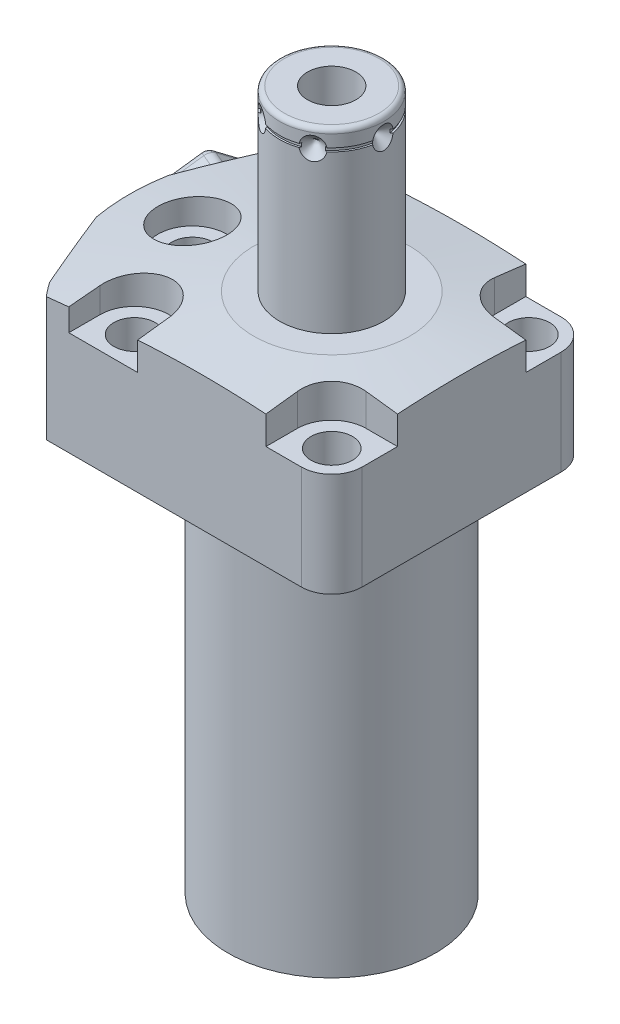
from build123d import *

# Parameters (mm, degrees)
CUT_EXTRUDE1_DEPTH       = 32.9946
CUT_EXTRUDE2_DEPTH       = 30.1498
CUT_EXTRUDE3_DEPTH       = 32.9946
FILLET1_R                = 6.477
CUT_EXTRUDE4_DEPTH       = 8.001
SKETCH11_R               = 2.7432
EXTRUDE1_DEPTH           = 2.9972
CUT_EXTRUDE5_DEPTH       = 1.27
CHAMFER1_SIZE            = 0.254
CHAMFER1_OF_MIRROR2_SIZE = 0.254
SKETCH16_R               = 1
SKETCH19_R               = 8.5
EXTRUDE3_DEPTH           = 1
SKETCH22_W               = 0.381
SKETCH22_H               = 0.762
HOLE1_AT_2_COUNT         = 2
HOLE1_AT_2_PITCH         = 54.877785999
HOLE1_AT_3_COUNT         = 2
HOLE1_AT_3_PITCH         = 54.877785999
HOLE1_AT_4_COUNT         = 2
HOLE1_AT_4_PITCH         = 22.73112685
HOLE1_AT_5_COUNT         = 2
HOLE1_AT_5_PITCH         = 22.73112685
SKETCH25_R               = 11.3665
CUT_EXTRUDE7_DEPTH       = 1.524
EXTRUDE4_DEPTH           = 7.471
FILLET2_R                = 2
CIRPATTERN1_COUNT        = 6


with BuildPart() as part:
    # S2D0002 → Revolve1 (revolve)
    with BuildSketch(Plane.XY, mode=Mode.PRIVATE) as revolve1_sk:
        Polygon((-43.18, 0), (-43.18, 30.1498), (0, 30.1498), (0, -80.9752), (-22.098, -80.9752), (-22.098, 0), align=None)
    revolve(revolve1_sk.sketch.rotate(Axis((0, -3.4925, 0), (0, 1, 0)), 270), axis=Axis((0, -3.4925, 0), (0, 1, 0)))  # turned: the seam where the file's is

    # S2D0001 → Cut-Extrude1 (cut)
    with BuildSketch(Plane.XZ):
        with BuildLine():
            Line((-33.136049915, -27.686), (33.136049915, -27.686))
            ThreePointArc((33.136049915, -27.686), (0, -43.18), (-33.136049915, -27.686))
        make_face()
        with BuildLine():
            Line((33.136049915, 27.686), (-33.136049915, 27.686))
            ThreePointArc((-33.136049915, 27.686), (0, 43.18), (33.136049915, 27.686))
        make_face()
    extrude(amount=-CUT_EXTRUDE1_DEPTH, mode=Mode.SUBTRACT)

    # Sketch3 → Cut-Extrude2 (cut)
    with BuildSketch(Plane(origin=(0, 30.1498, 0), x_dir=(-1, 0, 0), z_dir=(0, -1, 0))):
        with BuildLine():
            Line((21.331674578, 58.746997027), (45.665477495, 0))
            Line((45.665477495, 0), (21.331674578, -58.746997027))
            ThreePointArc((21.331674578, -58.746997027), (62.5, 0), (21.331674578, 58.746997027))
        make_face()
    extrude(amount=CUT_EXTRUDE2_DEPTH, mode=Mode.SUBTRACT)

    # Sketch4 → Cut-Extrude3 (cut)
    with BuildSketch(Plane.XZ):
        with BuildLine():
            Line((27.686, -33.136049915), (27.686, 33.136049915))
            ThreePointArc((27.686, 33.136049915), (43.18, 0), (27.686, -33.136049915))
        make_face()
    extrude(amount=-CUT_EXTRUDE3_DEPTH, mode=Mode.SUBTRACT)

    # Fillet1
    fillet1_edges = [part.edges().sort_by_distance(p)[0] for p in [
        (27.686, 15.0749, 27.686),
        (27.686, 15.0749, -27.686),
    ]]
    fillet(fillet1_edges, radius=FILLET1_R)

    # Sketch5 → Cut-Extrude4 (cut)
    with BuildSketch(Plane(origin=(0, 30.1498, 0), x_dir=(-1, 0, 0), z_dir=(0, 1, 0))):
        with BuildLine():
            Line((-27.686, -13.6652), (-27.686, -27.686))
            Line((-27.686, -27.686), (-13.6652, -27.686))
            Line((-13.6652, -27.686), (-13.6652, -21.0058))
            ThreePointArc((-13.6652, -21.0058), (-15.815211962, -15.815211962), (-21.0058, -13.6652))
            Line((-21.0058, -13.6652), (-27.686, -13.6652))
        make_face()
        with BuildLine():
            Line((-13.6652, 21.0058), (-13.6652, 27.686))
            Line((-13.6652, 27.686), (-27.686, 27.686))
            Line((-27.686, 27.686), (-27.686, 13.6652))
            Line((-27.686, 13.6652), (-21.0058, 13.6652))
            ThreePointArc((-21.0058, 13.6652), (-15.815211962, 15.815211962), (-13.6652, 21.0058))
        make_face()
        with BuildLine():
            Line((13.6652, 27.686), (28.3464, 27.686))
            Line((28.3464, 27.686), (28.3464, 21.0058))
            ThreePointArc((28.3464, 21.0058), (21.0058, 13.6652), (13.6652, 21.0058))
            Line((13.6652, 21.0058), (13.6652, 27.686))
        make_face()
        with BuildLine():
            Line((13.6652, -27.686), (13.6652, -21.0058))
            ThreePointArc((13.6652, -21.0058), (21.0058, -13.6652), (28.3464, -21.0058))
            Line((28.3464, -21.0058), (28.3464, -27.686))
            Line((28.3464, -27.686), (13.6652, -27.686))
        make_face()
    extrude(amount=-CUT_EXTRUDE4_DEPTH, mode=Mode.SUBTRACT)

    # S2D0003 → Cut-Revolve1 (revolve, cut)
    with BuildSketch(Plane.XY, mode=Mode.PRIVATE) as cut_revolve1_sk:
        Polygon((-16.637, 30.1498), (-86.637, 20.311941571), (-86.637, 30.1498), align=None)
    revolve(cut_revolve1_sk.sketch.rotate(Axis((0, 12.958028823, 0), (0, 1, 0)), 270), axis=Axis((0, 12.958028823, 0), (0, 1, 0)), mode=Mode.SUBTRACT)  # turned: the seam where the file's is

    # Sketch7 → Cut-Revolve2 (revolve, cut)
    with BuildSketch(Plane.XZ.offset(-14.5034)):
        Polygon((-41.173297543, -10.181347778), (-42.857104646, -6.116277835), (-43.091770047, -6.213479427), (-38.977923149, -16.145184401), (-25.648928357, -10.624133986), (-27.923445606, -5.132963597), (-40.549917486, -10.363019494), (-41.04563442, -10.157686817), align=None)
    cut_revolve2 = revolve(axis=Axis((0, 14.5034, 0), (0.923879533, 0, 0.382683432)), mode=Mode.SUBTRACT)

    # Sketch9 → Cut-Revolve4 (revolve, cut)
    with BuildSketch(Plane.XY.offset(-11.8364), mode=Mode.PRIVATE) as cut_revolve4_sk:
        Polygon((-31.8262, 1.5), (-33.575, 1.5), (-33.575, 0), (-28.575, 0), (-28.575, 12.0664), (-29.8196, 12.0664), (-29.8196, 4.4972), (-31.8262, 4.4972), align=None)
    cut_revolve4 = revolve(cut_revolve4_sk.sketch.rotate(Axis((-28.575, -17.893386483, -11.8364), (0, 1, 0)), 180), axis=Axis((-28.575, -17.893386483, -11.8364), (0, 1, 0)), mode=Mode.SUBTRACT)  # turned: the seam where the file's is

    # Sketch11 → Extrude1 (add)
    with BuildSketch(Plane.XZ.offset(-4.4972)):
        with Locations(Location((-28.575, -11.8364, 0), (0, 0, 270))):  # turned: the seam where the file's is
            Circle(SKETCH11_R)
    extrude1 = extrude(amount=EXTRUDE1_DEPTH)

    # Sketch12 → Cut-Extrude5 (cut)
    with BuildSketch(Plane.XZ.offset(-1.5)):
        Polygon((-27.3304, -12.554970145), (-27.3304, -11.117829855), (-28.575, -10.39925971), (-29.8196, -11.117829855), (-29.8196, -12.554970145), (-28.575, -13.27354029), align=None)
    cut_extrude5 = extrude(amount=-CUT_EXTRUDE5_DEPTH, mode=Mode.SUBTRACT)

    # Chamfer1
    chamfer1_edges = [part.edges().sort_by_distance(p)[0] for p in [
        (-28.575, 1.5, -9.0932),
    ]]
    chamfer(chamfer1_edges, length=CHAMFER1_SIZE)

    # Mirror2: Cut-Revolve2, Cut-Revolve4, Extrude1, Cut-Extrude5 across plane
    add(cut_revolve2.mirror(Plane.XY), mode=Mode.SUBTRACT)
    add(cut_revolve4.mirror(Plane.XY), mode=Mode.SUBTRACT)
    add(extrude1.mirror(Plane.XY))
    add(cut_extrude5.mirror(Plane.XY), mode=Mode.SUBTRACT)

    # Chamfer1 of Mirror2
    chamfer1_of_mirror2_edges = [part.edges().sort_by_distance(p)[0] for p in [
        (-28.575, 1.5, 9.0932),
    ]]
    chamfer(chamfer1_of_mirror2_edges, length=CHAMFER1_OF_MIRROR2_SIZE)

    # Sketch17 → Revolve4 (revolve)
    with BuildSketch(Plane(origin=(0, 0, 0), x_dir=(0, 0, -1), z_dir=(1, 0, 0)), mode=Mode.PRIVATE) as revolve4_sk:
        with BuildLine():
            Line((0, 30.1498), (-11.1125, 30.1498))
            Line((-11.1125, 30.1498), (-11.1125, 67.018))
            ThreePointArc((-11.1125, 67.018), (-10.81492049, 67.73642049), (-10.0965, 68.034))
            Line((-10.0965, 68.034), (0, 68.034))
            Line((0, 68.034), (0, 30.1498))
        make_face()
    revolve(revolve4_sk.sketch.rotate(Axis((0, 24.99613, 0), (0, 1, 0)), 180), axis=Axis((0, 24.99613, 0), (0, 1, 0)))  # turned: the seam where the file's is

    # Sketch18 → Cut-Revolve7 (revolve, cut)
    with BuildSketch(Plane.XY, mode=Mode.PRIVATE) as cut_revolve7_sk:
        Polygon((5.1562, 68.034), (5.1562, 51.016), (0, 47.917842476), (0, 68.034), align=None)
    revolve(cut_revolve7_sk.sketch.rotate(Axis((0, -20.475979697, 0), (0, 1, 0)), 90), axis=Axis((0, -20.475979697, 0), (0, 1, 0)), mode=Mode.SUBTRACT)  # turned: the seam where the file's is

    # Sketch19 → Extrude3 (add)
    with BuildSketch(Plane(origin=(-52.256800889, 0, 16.576596317), x_dir=(-0.382683432, 0, 0.923879533), z_dir=(-0.923879533, 0, -0.382683432))):
        with Locations((-35.312589984, 14.5034)):
            Circle(SKETCH19_R)
    extrude(amount=EXTRUDE3_DEPTH)

    # Sketch20 → Cut-Revolve8 (revolve, cut)
    with BuildSketch(Plane.XY, mode=Mode.PRIVATE) as cut_revolve8_sk:
        Polygon((-11.1125, 61.6586), (-11.1125, 64.0716), (-8.6995, 64.0716), align=None)
    cut_revolve8 = revolve(cut_revolve8_sk.sketch.rotate(Axis((0, 64.0716, 0), (1, 0, 0)), 270), axis=Axis((0, 64.0716, 0), (1, 0, 0)), mode=Mode.SUBTRACT)  # turned: the seam where the file's is

    # Sketch22 → Cut-Revolve6 (revolve, cut)
    with BuildSketch(Plane(origin=(0, 0, 0), x_dir=(0, 0, -1), z_dir=(1, 0, 0))):
        with Locations((10.922, 64.072)):
            Rectangle(SKETCH22_W, SKETCH22_H)
    revolve(axis=Axis((0, 41.8979, 0), (0, 1, 0)), mode=Mode.SUBTRACT)

    # Sketch23 → Hole1 (revolve, cut)
    with BuildSketch(Plane(origin=(-29.6926, 30.1498, 0), x_dir=(0, 0, 1), z_dir=(1, 0, 0))):
        Polygon((0, 0), (0, 30.1498), (4.4196, 30.1498), (4.4196, 8.001), (7.3406, 8.001), (7.3406, 0), align=None)
    hole1 = revolve(axis=Axis((-29.6926, -79.8502, 0), (0, 1, 0)), mode=Mode.SUBTRACT)

    # Hole1 at 2: Hole1 ×2
    with Locations(*[Vector(0.923841935, 0, 0.382774188) * (i * HOLE1_AT_2_PITCH) for i in range(1, HOLE1_AT_2_COUNT)]):
        add(hole1, mode=Mode.SUBTRACT)

    # Hole1 at 3: Hole1 ×2
    with Locations(*[Vector(0.923841935, 0, -0.382774188) * (i * HOLE1_AT_3_PITCH) for i in range(1, HOLE1_AT_3_COUNT)]):
        add(hole1, mode=Mode.SUBTRACT)

    # Hole1 at 4: Hole1 ×2
    with Locations(*[Vector(0.382154394, 0, 0.92409849) * (i * HOLE1_AT_4_PITCH) for i in range(1, HOLE1_AT_4_COUNT)]):
        add(hole1, mode=Mode.SUBTRACT)

    # Hole1 at 5: Hole1 ×2
    with Locations(*[Vector(0.382154394, 0, -0.92409849) * (i * HOLE1_AT_5_PITCH) for i in range(1, HOLE1_AT_5_COUNT)]):
        add(hole1, mode=Mode.SUBTRACT)

    # Sketch25 → Cut-Extrude7 (cut)
    with BuildSketch(Plane.XZ.offset(80.9752)):
        with Locations(Location((0, 0, 0), (0, 0, 270))):  # turned: the seam where the file's is
            Circle(SKETCH25_R)
    extrude(amount=-CUT_EXTRUDE7_DEPTH, mode=Mode.SUBTRACT)

    # Sketch27 → Extrude4 (add)
    with BuildSketch(Plane(origin=(-39.66713728, 0, -16.430666242), x_dir=(-0.382683432, 0, 0.923879533), z_dir=(-0.923879533, 0, -0.382683432))):
        Polygon((8.399828748, 19.580427707), (-0.196920596, 24.316378937), (-8.596749344, 19.239351229), (-8.399828748, 9.426372293), (0.196920596, 4.690421063), (8.596749344, 9.767448771), align=None)
    extrude(amount=EXTRUDE4_DEPTH)

    # Fillet2
    fillet2_edges = [part.edges().sort_by_distance(p)[0] for p in [
        (-46.40812282, 9.767448771, -9.917819438),
        (-46.33276457, 19.580427707, -10.099750347),
        (-43.042931024, 24.316378937, -18.042111112),
        (-39.828455728, 19.239351229, -25.802540969),
        (-39.903813977, 9.426372293, -25.62061006),
        (-43.193647524, 4.690421063, -17.678249295),
        (-49.821595689, 14.673938239, -11.438298854),
        (-48.138999791, 21.948403322, -15.500444691),
        (-44.88684537, 21.777865083, -23.351840002),
        (-43.317286846, 14.332861761, -27.141089476),
        (-44.999882744, 7.058396678, -23.078943639),
        (-48.252037166, 7.228934917, -15.227548328),
    ]]
    fillet(fillet2_edges, radius=FILLET2_R)

    # CirPattern1: Cut-Revolve8 ×6 about axis
    cirpattern1_axis = Axis((0, -3.4925, 0), (0, 1, 0))
    for i in range(1, CIRPATTERN1_COUNT):
        add(cut_revolve8.rotate(cirpattern1_axis, i * 360 / CIRPATTERN1_COUNT), mode=Mode.SUBTRACT)


with BuildPart() as body_2:
    # Sketch16 → Revolve3 (revolve)
    with BuildSketch(Plane(origin=(-18.1864, 0, -11.8364), x_dir=(-1, 0, 0), z_dir=(0, 0, -1)), mode=Mode.PRIVATE) as revolve3_sk:
        with Locations((14.3886, 0.5)):
            Circle(SKETCH16_R)
    revolve(revolve3_sk.sketch.rotate(Axis((-28.575, -0.4101, -11.8364), (0, 1, 0)), 180), axis=Axis((-28.575, -0.4101, -11.8364), (0, 1, 0)))  # turned: the seam where the file's is


with BuildPart() as body_3:
    # Mirror3: mirrored copy
    add(body_2.part.mirror(Plane.XY))


solid = Compound([part.part, body_2.part, body_3.part])
